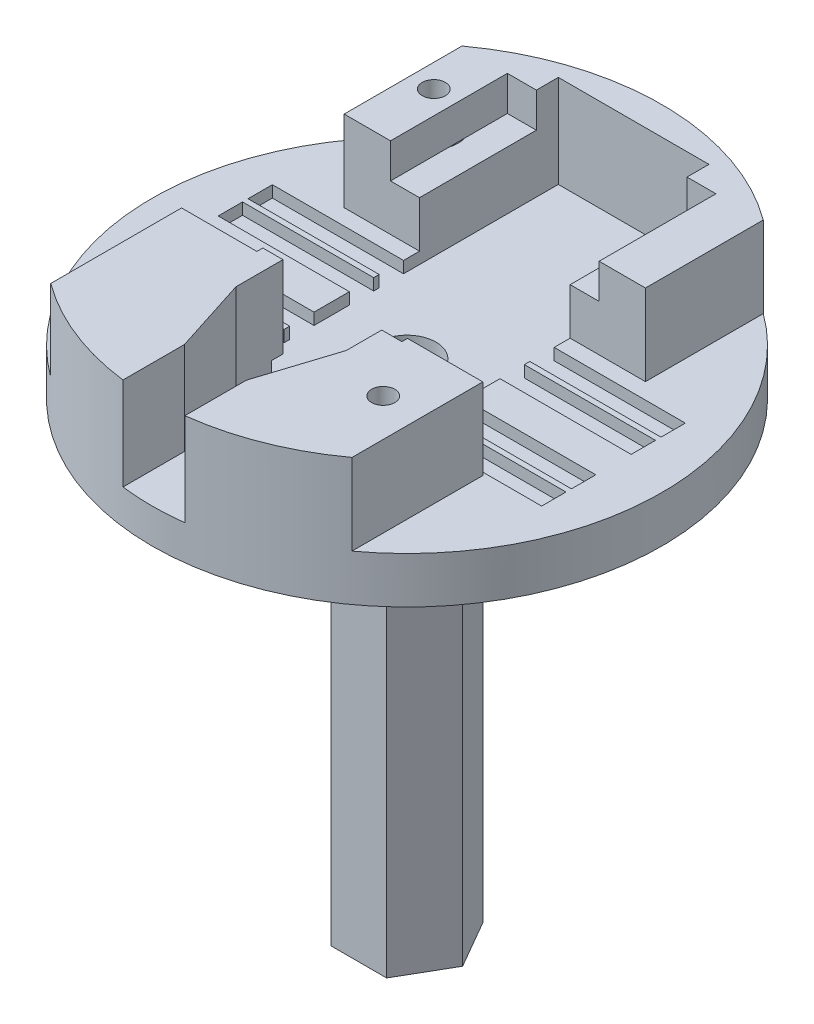
from build123d import *

# Parameters (mm, degrees)
BOSS_EXTRUDE1_DEPTH      = 9
BOSS_EXTRUDE1_DEPTH_BACK = 2
SKETCH1_R                = 22
SKETCH6_R                = 21
SKETCH6_R_2              = 12.5
CUT_EXTRUDE5_DEPTH       = 1
SKETCH7_R                = 8.5
BOSS_EXTRUDE2_DEPTH      = 40
CUT_EXTRUDE6_DEPTH       = 51.675437837
CUT_EXTRUDE6_DEPTH_BACK  = 51.675437837
SKETCH8_R                = 1.5
CUT_EXTRUDE7_DEPTH       = 7
SKETCH17_R               = 2.496785081
CUT_EXTRUDE14_DEPTH      = 62
SKETCH29_W               = 18
SKETCH29_H               = 24.118038922
CUT_EXTRUDE19_DEPTH      = 3
SKETCH30_W               = 2.5
SKETCH30_H               = 14
CUT_EXTRUDE20_DEPTH      = 6
BOSS_EXTRUDE4_DEPTH      = 2
BOSS_EXTRUDE4_DEPTH_BACK = 2
SKETCH35_R               = 9.1
SKETCH35_R_2             = 8.5
CUT_EXTRUDE28_DEPTH      = 1.5
CUT_EXTRUDE28_DEPTH_BACK = 1.5
SKETCH36_R               = 8.5
SKETCH36_R_2             = 8.3
CUT_EXTRUDE30_DEPTH      = 1.5
CUT_EXTRUDE30_DEPTH_BACK = 1.5
SKETCH39_R               = 8.5
SKETCH39_R_2             = 8.3
CUT_EXTRUDE31_DEPTH      = 1.5
CUT_EXTRUDE31_DEPTH_BACK = 1.5
SKETCH40_R               = 8.5
SKETCH40_R_2             = 8.3
CUT_EXTRUDE32_DEPTH      = 1.5
CUT_EXTRUDE32_DEPTH_BACK = 1.5
SKETCH41_R               = 8.5
SKETCH41_R_2             = 8.35
CUT_EXTRUDE33_DEPTH      = 1.5
CUT_EXTRUDE33_DEPTH_BACK = 1.5
SKETCH42_R               = 8.5
SKETCH42_R_2             = 8.3
CUT_EXTRUDE34_DEPTH      = 1.5
CUT_EXTRUDE34_DEPTH_BACK = 1.5
SKETCH43_R               = 8.5
SKETCH43_R_2             = 8.3
CUT_EXTRUDE35_DEPTH      = 53.268537381
CUT_EXTRUDE35_DEPTH_BACK = 53.268537381
SKETCH44_R               = 1
CUT_EXTRUDE36_DEPTH      = 53.268537462
CUT_EXTRUDE36_DEPTH_BACK = 53.268537462
SKETCH45_R               = 1
CUT_EXTRUDE37_DEPTH      = 53.268537462
CUT_EXTRUDE37_DEPTH_BACK = 53.268537462
SKETCH46_R               = 1
SKETCH47_W               = 27.732128476
SKETCH47_H               = 14.033639909
CUT_EXTRUDE38_DEPTH      = 7
CUT_EXTRUDE39_DEPTH      = 8
SKETCH48_R               = 1
CUT_EXTRUDE40_DEPTH      = 9
SKETCH50_R               = 6.388253867
BOSS_EXTRUDE5_DEPTH      = 2
SKETCH49_R               = 2.1
CUT_EXTRUDE42_DEPTH      = 7
SKETCH51_W               = 35.63730279
SKETCH51_H               = 2.1
CUT_EXTRUDE43_DEPTH      = 1
SKETCH53_R               = 9.1
CUT_EXTRUDE45_DEPTH      = 40
SKETCH55_W               = 1.737607108
SKETCH55_H               = 7.054348591
BOSS_EXTRUDE6_DEPTH      = 1
BOSS_EXTRUDE9_DEPTH      = 40
BOSS_EXTRUDE9_DEPTH_BACK = 2


with BuildPart() as part:
    # Sketch1 → Boss-Extrude1 (new, two sides: drawn at the far end of the back side and taken through both)
    with BuildSketch(Plane(origin=(0, 0, 0), x_dir=(1, 0, 0), z_dir=(0, 1, 0)).offset(-BOSS_EXTRUDE1_DEPTH_BACK)):
        Circle(SKETCH1_R)
    extrude(amount=BOSS_EXTRUDE1_DEPTH + BOSS_EXTRUDE1_DEPTH_BACK)

    # Sketch6 → Cut-Extrude5 (cut)
    with BuildSketch(Plane(origin=(0, -2, 0), x_dir=(-1, 0, 0), z_dir=(0, -1, 0))):
        Circle(SKETCH6_R)
        Circle(SKETCH6_R_2, mode=Mode.SUBTRACT)
    extrude(amount=-CUT_EXTRUDE5_DEPTH, mode=Mode.SUBTRACT)

    # Sketch7 → Boss-Extrude2 (add)
    with BuildSketch(Plane(origin=(0, -2, 0), x_dir=(-1, 0, 0), z_dir=(0, -1, 0))):
        Circle(SKETCH7_R)
    extrude(amount=BOSS_EXTRUDE2_DEPTH)

    # Sketch8 → Cut-Extrude6 (cut, two sides: drawn at the far end of the back side and taken through both)
    with BuildSketch(Plane(origin=(0, -2, 0), x_dir=(-1, 0, 0), z_dir=(0, -1, 0)).offset(-CUT_EXTRUDE6_DEPTH_BACK)):
        Circle(SKETCH8_R)
    extrude(amount=CUT_EXTRUDE6_DEPTH + CUT_EXTRUDE6_DEPTH_BACK, mode=Mode.SUBTRACT)

    # Sketch9 → Cut-Extrude7 (cut)
    with BuildSketch(Plane(origin=(0, 9, 0), x_dir=(1, 0, 0), z_dir=(0, 1, 0))):
        with BuildLine():
            Line((-13.000713231, -20.359249211), (-13.000713231, 20.359249211))
            ThreePointArc((-13.000713231, 20.359249211), (-24.156108398, 0), (-13.000713231, -20.359249211))
        make_face()
        with BuildLine():
            Line((13, -20.359704638), (13, 20.359704638))
            ThreePointArc((13, 20.359704638), (24.156108398, 0), (13, -20.359704638))
        make_face()
    extrude(amount=-CUT_EXTRUDE7_DEPTH, mode=Mode.SUBTRACT)

    # Sketch17 → Cut-Extrude14 (cut)
    with BuildSketch(Plane(origin=(0, -42, 0), x_dir=(-1, 0, 0), z_dir=(0, -1, 0))):
        Circle(SKETCH17_R)
    extrude(amount=-CUT_EXTRUDE14_DEPTH, mode=Mode.SUBTRACT)

    # Sketch29 → Cut-Extrude19 (cut)
    with BuildSketch(Plane(origin=(0, 9, 0), x_dir=(1, 0, 0), z_dir=(0, 1, 0))):
        with Locations((0, 5.603215798)):
            Rectangle(SKETCH29_W, SKETCH29_H)
    extrude(amount=-CUT_EXTRUDE19_DEPTH, mode=Mode.SUBTRACT)

    # Sketch30 → Cut-Extrude20 (cut)
    with BuildSketch(Plane(origin=(0, 9, 0), x_dir=(1, 0, 0), z_dir=(0, 1, 0))):
        with Locations((6.752146467, 0.544196337)):
            Rectangle(SKETCH30_W, SKETCH30_H)
        with Locations((-6.752146467, 0.544196337)):
            Rectangle(SKETCH30_W, SKETCH30_H)
    extrude(amount=-CUT_EXTRUDE20_DEPTH, mode=Mode.SUBTRACT)

    # Sketch35 → Boss-Extrude4 (add, two sides: drawn at the far end of the back side and taken through both)
    with BuildSketch(Plane(origin=(0, -6.5, 0), x_dir=(1, 0, 0), z_dir=(0, 1, 0)).offset(-BOSS_EXTRUDE4_DEPTH_BACK)):
        Circle(SKETCH35_R)
        Circle(SKETCH35_R_2, mode=Mode.SUBTRACT)
    extrude(amount=BOSS_EXTRUDE4_DEPTH + BOSS_EXTRUDE4_DEPTH_BACK)

    # Sketch36 → Cut-Extrude28 (cut, two sides: drawn at the far end of the back side and taken through both)
    with BuildSketch(Plane(origin=(0, -17, 0), x_dir=(1, 0, 0), z_dir=(0, 1, 0)).offset(-CUT_EXTRUDE28_DEPTH_BACK)):
        Circle(SKETCH36_R)
        Circle(SKETCH36_R_2, mode=Mode.SUBTRACT)
    extrude(amount=CUT_EXTRUDE28_DEPTH + CUT_EXTRUDE28_DEPTH_BACK, mode=Mode.SUBTRACT)

    # Sketch39 → Cut-Extrude30 (cut, two sides: drawn at the far end of the back side and taken through both)
    with BuildSketch(Plane(origin=(0, -21, 0), x_dir=(1, 0, 0), z_dir=(0, 1, 0)).offset(-CUT_EXTRUDE30_DEPTH_BACK)):
        Circle(SKETCH39_R)
        Circle(SKETCH39_R_2, mode=Mode.SUBTRACT)
    extrude(amount=CUT_EXTRUDE30_DEPTH + CUT_EXTRUDE30_DEPTH_BACK, mode=Mode.SUBTRACT)

    # Sketch40 → Cut-Extrude31 (cut, two sides: drawn at the far end of the back side and taken through both)
    with BuildSketch(Plane(origin=(0, -25, 0), x_dir=(1, 0, 0), z_dir=(0, 1, 0)).offset(-CUT_EXTRUDE31_DEPTH_BACK)):
        Circle(SKETCH40_R)
        Circle(SKETCH40_R_2, mode=Mode.SUBTRACT)
    extrude(amount=CUT_EXTRUDE31_DEPTH + CUT_EXTRUDE31_DEPTH_BACK, mode=Mode.SUBTRACT)

    # Sketch41 → Cut-Extrude32 (cut, two sides: drawn at the far end of the back side and taken through both)
    with BuildSketch(Plane(origin=(0, -29, 0), x_dir=(1, 0, 0), z_dir=(0, 1, 0)).offset(-CUT_EXTRUDE32_DEPTH_BACK)):
        Circle(SKETCH41_R)
        Circle(SKETCH41_R_2, mode=Mode.SUBTRACT)
    extrude(amount=CUT_EXTRUDE32_DEPTH + CUT_EXTRUDE32_DEPTH_BACK, mode=Mode.SUBTRACT)

    # Sketch42 → Cut-Extrude33 (cut, two sides: drawn at the far end of the back side and taken through both)
    with BuildSketch(Plane(origin=(0, -33, 0), x_dir=(1, 0, 0), z_dir=(0, 1, 0)).offset(-CUT_EXTRUDE33_DEPTH_BACK)):
        Circle(SKETCH42_R)
        Circle(SKETCH42_R_2, mode=Mode.SUBTRACT)
    extrude(amount=CUT_EXTRUDE33_DEPTH + CUT_EXTRUDE33_DEPTH_BACK, mode=Mode.SUBTRACT)

    # Sketch43 → Cut-Extrude34 (cut, two sides: drawn at the far end of the back side and taken through both)
    with BuildSketch(Plane(origin=(0, -37, 0), x_dir=(1, 0, 0), z_dir=(0, 1, 0)).offset(-CUT_EXTRUDE34_DEPTH_BACK)):
        Circle(SKETCH43_R)
        Circle(SKETCH43_R_2, mode=Mode.SUBTRACT)
    extrude(amount=CUT_EXTRUDE34_DEPTH + CUT_EXTRUDE34_DEPTH_BACK, mode=Mode.SUBTRACT)

    # Sketch44 → Cut-Extrude35 (cut, two sides: drawn at the far end of the back side and taken through both)
    with BuildSketch(Plane.XY.offset(-CUT_EXTRUDE35_DEPTH_BACK)):
        with Locations((0, -16.975647938)):
            Circle(SKETCH44_R)
        with Locations((0, -29.042179734)):
            Circle(SKETCH44_R)
    extrude(amount=CUT_EXTRUDE35_DEPTH + CUT_EXTRUDE35_DEPTH_BACK, mode=Mode.SUBTRACT)

    # Sketch45 → Cut-Extrude36 (cut, two sides: drawn at the far end of the back side and taken through both)
    with BuildSketch(Plane(origin=(0, 0, 0), x_dir=(0, 1, 0), z_dir=(0.8660254037844398, 0, 0.499999999999998)).offset(-CUT_EXTRUDE36_DEPTH_BACK)):
        with Locations((-21.101513607, 0)):
            Circle(SKETCH45_R)
        with Locations((-33.049455879, 0)):
            Circle(SKETCH45_R)
    extrude(amount=CUT_EXTRUDE36_DEPTH + CUT_EXTRUDE36_DEPTH_BACK, mode=Mode.SUBTRACT)

    # Sketch46 → Cut-Extrude37 (cut, two sides: drawn at the far end of the back side and taken through both)
    with BuildSketch(Plane(origin=(0, 0, 0), x_dir=(0, 1, 0), z_dir=(0.8660254037844364, 0, -0.500000000000004)).offset(-CUT_EXTRUDE37_DEPTH_BACK)):
        with Locations((-24.961001523, 0)):
            Circle(SKETCH46_R)
        with Locations((-37.130366549, 0)):
            Circle(SKETCH46_R)
    extrude(amount=CUT_EXTRUDE37_DEPTH + CUT_EXTRUDE37_DEPTH_BACK, mode=Mode.SUBTRACT)

    # Sketch47 → Cut-Extrude38 (cut)
    with BuildSketch(Plane(origin=(0, 9, 0), x_dir=(1, 0, 0), z_dir=(0, 1, 0))):
        with Locations((-0.011675811, 0.561016292)):
            Rectangle(SKETCH47_W, SKETCH47_H)
    extrude(amount=-CUT_EXTRUDE38_DEPTH, mode=Mode.SUBTRACT)

    # Sketch23 → Cut-Extrude39 (cut)
    with BuildSketch(Plane(origin=(0, 9, 0), x_dir=(1, 0, 0), z_dir=(0, 1, 0))):
        with BuildLine():
            Line((-2.670420152, -16.85816067), (-2.670420152, -16.530371213))
            Line((-2.670420152, -16.530371213), (-4.762392892, -10))
            Line((-4.762392892, -10), (-4.762392892, -6.943148259))
            Line((-4.762392892, -6.943148259), (-6.5, -6.943148259))
            Line((-6.5, -6.943148259), (-6.5, 19.556851741))
            Line((-6.5, 19.556851741), (6.5, 19.556851741))
            Line((6.5, 19.556851741), (6.5, -6.943148259))
            Line((6.5, -6.943148259), (4.762392892, -6.943148259))
            Line((4.762392892, -6.943148259), (4.762392892, -10))
            Line((4.762392892, -10), (2.670420152, -16.530371213))
            Line((2.670420152, -16.530371213), (2.670420152, -16.85816067))
            Line((2.670420152, -16.85816067), (2.670420152, -21.837327131))
            ThreePointArc((2.670420152, -21.837327131), (1.836835043, -21.92318492), (1.000584871, -21.977234355))
            Line((1.000584871, -21.977234355), (0, -25.25))
            Line((0, -25.25), (-1.000584871, -21.977234355))
            ThreePointArc((-1.000584871, -21.977234355), (-1.836835043, -21.92318492), (-2.670420152, -21.837327131))
            Line((-2.670420152, -21.837327131), (-2.670420152, -16.85816067))
        make_face()
    extrude(amount=-CUT_EXTRUDE39_DEPTH, mode=Mode.SUBTRACT)

    # Sketch48 → Cut-Extrude40 (cut)
    with BuildSketch(Plane(origin=(0, 9, 0), x_dir=(1, 0, 0), z_dir=(0, 1, 0))):
        with Locations((-11, 13.315197565)):
            Circle(SKETCH48_R)
        with Locations((9.750356615, -11.802538605)):
            Circle(SKETCH48_R)
    extrude(amount=-CUT_EXTRUDE40_DEPTH, mode=Mode.SUBTRACT)

    # Sketch50 → Boss-Extrude5 (add)
    with BuildSketch(Plane.XZ.offset(42)):
        Circle(SKETCH50_R)
        Polygon((-4.989659815, -0.000576747), (-2.49433043, -4.321460529), (2.495329385, -4.320883782), (4.989659815, 0.000576747), (2.49433043, 4.321460529), (-2.495329385, 4.320883782), align=None, mode=Mode.SUBTRACT)
    extrude(amount=-BOSS_EXTRUDE5_DEPTH)

    # Sketch49 → Cut-Extrude42 (cut)
    with BuildSketch(Plane.XZ.offset(1)):
        with Locations((-11, -13.315197565)):
            Circle(SKETCH49_R)
        with Locations((9.750356615, 11.802538605)):
            Circle(SKETCH49_R)
    extrude(amount=-CUT_EXTRUDE42_DEPTH, mode=Mode.SUBTRACT)

    # Sketch51 → Cut-Extrude43 (cut)
    with BuildSketch(Plane(origin=(0, 2, 0), x_dir=(1, 0, 0), z_dir=(0, 1, 0))):
        with Locations((0, 5.15)):
            Rectangle(SKETCH51_W, SKETCH51_H)
        with Locations((0, 2.575)):
            Rectangle(SKETCH51_W, SKETCH51_H)
        with Locations((0, -2.575)):
            Rectangle(SKETCH51_W, SKETCH51_H)
        with Locations((0, -5.15)):
            Rectangle(SKETCH51_W, SKETCH51_H)
    extrude(amount=-CUT_EXTRUDE43_DEPTH, mode=Mode.SUBTRACT)

    # Sketch53 → Cut-Extrude45 (cut)
    with BuildSketch(Plane.XZ.offset(42)):
        Circle(SKETCH53_R)
    extrude(amount=-CUT_EXTRUDE45_DEPTH, mode=Mode.SUBTRACT)

    # Sketch55 → Boss-Extrude6 (add)
    with BuildSketch(Plane(origin=(0, 0, 6.943148259), x_dir=(-1, 0, 0), z_dir=(0, 0, -1))):
        Polygon((-4.762392892, 8), (-6.167287474, 8), (-6.167287474, 6), (-6.5, 6), (-6.5, 1.945651409), (-4.762392892, 1.945651409), align=None)
        with Locations((5.631196446, 5.472825704)):
            Rectangle(SKETCH55_W, SKETCH55_H)
    extrude(amount=BOSS_EXTRUDE6_DEPTH)


with BuildPart() as body_2:
    # Sketch56 → Boss-Extrude9 (new, two sides: drawn at the far end of the back side and taken through both)
    with BuildSketch(Plane.XZ.offset(2).offset(-BOSS_EXTRUDE9_DEPTH_BACK)):
        Polygon((2.399519492, 4.157199323), (-2.400480476, 4.156644498), (-4.799999968, -0.000554824), (-2.399519492, -4.157199323), (2.400480476, -4.156644498), (4.799999968, 0.000554824), align=None)
    extrude(amount=BOSS_EXTRUDE9_DEPTH + BOSS_EXTRUDE9_DEPTH_BACK)


solid = Compound([part.part, body_2.part])
